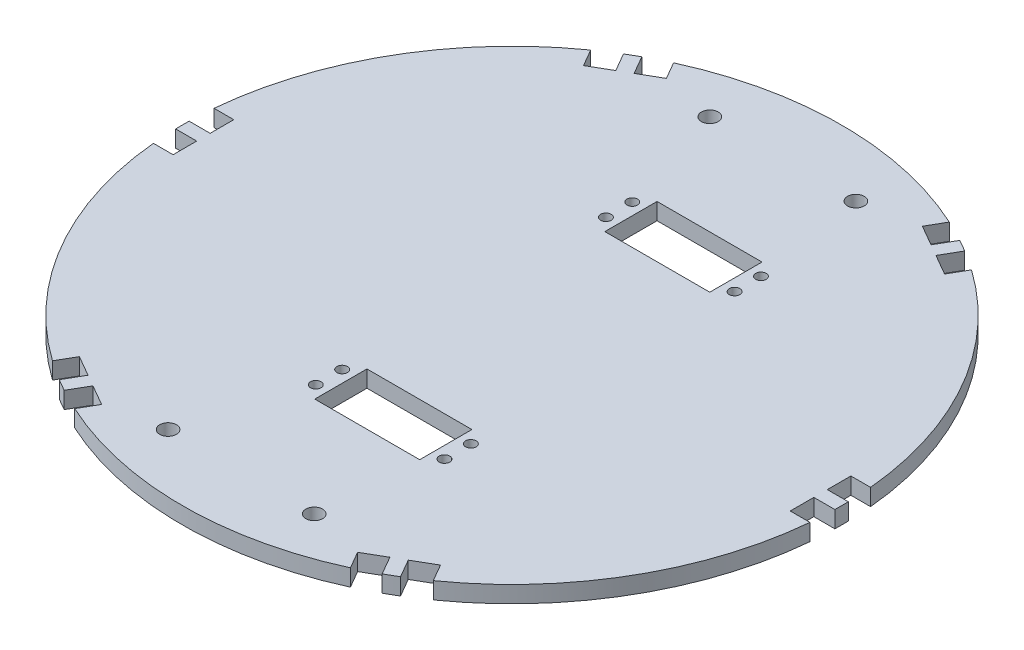
from build123d import *

# Parameters (mm, degrees)
SKETCH1_R           = 2
SKETCH1_W           = 39.8
SKETCH1_H           = 19.8
BOSS_EXTRUDE1_DEPTH = 6.35
SKETCH3_R           = 3.175
CUT_EXTRUDE1_DEPTH  = 6.35


with BuildPart() as part:
    # Sketch1 → Boss-Extrude1 (new body)
    with BuildSketch(Plane(origin=(0, 0, 0), x_dir=(1, 0, 0), z_dir=(0, 1, 0))):
        with BuildLine():
            Line((-124.469875874, 11.5), (-117, 11.5))
            Line((-117, 11.5), (-117, 2.55))
            Line((-117, 2.55), (-124.973987293, 2.55))
            ThreePointArc((-124.973987293, 2.55), (-125, 0), (-124.973987293, -2.55))
            Line((-124.973987293, -2.55), (-117, -2.55))
            Line((-117, -2.55), (-117, -11.5))
            Line((-117, -11.5), (-124.469875874, -11.5))
            ThreePointArc((-124.469875874, -11.5), (-108.253175473, -62.5), (-72.19423008, -102.044074512))
            Line((-72.19423008, -102.044074512), (-68.459292144, -95.574972243))
            Line((-68.459292144, -95.574972243), (-60.70836478, -100.049972243))
            Line((-60.70836478, -100.049972243), (-64.695358426, -106.955647808))
            ThreePointArc((-64.695358426, -106.955647808), (-62.5, -108.253175473), (-60.278628867, -109.505647808))
            Line((-60.278628867, -109.505647808), (-56.29163522, -102.599972243))
            Line((-56.29163522, -102.599972243), (-48.540707856, -107.074972243))
            Line((-48.540707856, -107.074972243), (-52.275645793, -113.544074512))
            ThreePointArc((-52.275645793, -113.544074512), (0, -125), (52.275645793, -113.544074512))
            Line((52.275645793, -113.544074512), (48.540707856, -107.074972243))
            Line((48.540707856, -107.074972243), (56.29163522, -102.599972243))
            Line((56.29163522, -102.599972243), (60.278628867, -109.505647808))
            ThreePointArc((60.278628867, -109.505647808), (62.5, -108.253175473), (64.695358426, -106.955647808))
            Line((64.695358426, -106.955647808), (60.70836478, -100.049972243))
            Line((60.70836478, -100.049972243), (68.459292144, -95.574972243))
            Line((68.459292144, -95.574972243), (72.19423008, -102.044074512))
            ThreePointArc((72.19423008, -102.044074512), (108.253175473, -62.5), (124.469875874, -11.5))
            Line((124.469875874, -11.5), (117, -11.5))
            Line((117, -11.5), (117, -2.55))
            Line((117, -2.55), (124.973987293, -2.55))
            ThreePointArc((124.973987293, -2.55), (125, 0), (124.973987293, 2.55))
            Line((124.973987293, 2.55), (117, 2.55))
            Line((117, 2.55), (117, 11.5))
            Line((117, 11.5), (124.469875874, 11.5))
            ThreePointArc((124.469875874, 11.5), (108.253175473, 62.5), (72.19423008, 102.044074512))
            Line((72.19423008, 102.044074512), (68.459292144, 95.574972243))
            Line((68.459292144, 95.574972243), (60.70836478, 100.049972243))
            Line((60.70836478, 100.049972243), (64.695358426, 106.955647808))
            ThreePointArc((64.695358426, 106.955647808), (62.5, 108.253175473), (60.278628867, 109.505647808))
            Line((60.278628867, 109.505647808), (56.29163522, 102.599972243))
            Line((56.29163522, 102.599972243), (48.540707856, 107.074972243))
            Line((48.540707856, 107.074972243), (52.275645793, 113.544074512))
            ThreePointArc((52.275645793, 113.544074512), (0, 125), (-52.275645793, 113.544074512))
            Line((-52.275645793, 113.544074512), (-48.540707856, 107.074972243))
            Line((-48.540707856, 107.074972243), (-56.29163522, 102.599972243))
            Line((-56.29163522, 102.599972243), (-60.278628867, 109.505647808))
            ThreePointArc((-60.278628867, 109.505647808), (-62.5, 108.253175473), (-64.695358426, 106.955647808))
            Line((-64.695358426, 106.955647808), (-60.70836478, 100.049972243))
            Line((-60.70836478, 100.049972243), (-68.459292144, 95.574972243))
            Line((-68.459292144, 95.574972243), (-72.19423008, 102.044074512))
            ThreePointArc((-72.19423008, 102.044074512), (-108.253175473, 62.5), (-124.469875874, 11.5))
        make_face()
        with Locations((34.4, 60)):
            Circle(SKETCH1_R, mode=Mode.SUBTRACT)
        with Locations((34.4, 50)):
            Circle(SKETCH1_R, mode=Mode.SUBTRACT)
        with Locations((-14.4, 60)):
            Circle(SKETCH1_R, mode=Mode.SUBTRACT)
        with Locations((-14.4, 50)):
            Circle(SKETCH1_R, mode=Mode.SUBTRACT)
        with Locations((-14.4, -60)):
            Circle(SKETCH1_R, mode=Mode.SUBTRACT)
        with Locations((-14.4, -50)):
            Circle(SKETCH1_R, mode=Mode.SUBTRACT)
        with Locations((34.4, -60)):
            Circle(SKETCH1_R, mode=Mode.SUBTRACT)
        with Locations((34.4, -50)):
            Circle(SKETCH1_R, mode=Mode.SUBTRACT)
        with Locations((10, 55)):
            Rectangle(SKETCH1_W, SKETCH1_H, mode=Mode.SUBTRACT)
        with Locations((10, -55)):
            Rectangle(SKETCH1_W, SKETCH1_H, mode=Mode.SUBTRACT)
    extrude(amount=BOSS_EXTRUDE1_DEPTH)

    # Sketch3 → Cut-Extrude1 (cut)
    with BuildSketch(Plane(origin=(0, 6.35, 0), x_dir=(1, 0, 0), z_dir=(0, 1, 0))):
        with Locations((-27.7, -102.7)):
            Circle(SKETCH3_R)
        with Locations((27.7, -102.7)):
            Circle(SKETCH3_R)
        with Locations((27.7, 102.7)):
            Circle(SKETCH3_R)
        with Locations((-27.7, 102.7)):
            Circle(SKETCH3_R)
    extrude(amount=-CUT_EXTRUDE1_DEPTH, mode=Mode.SUBTRACT)


solid = part.part
